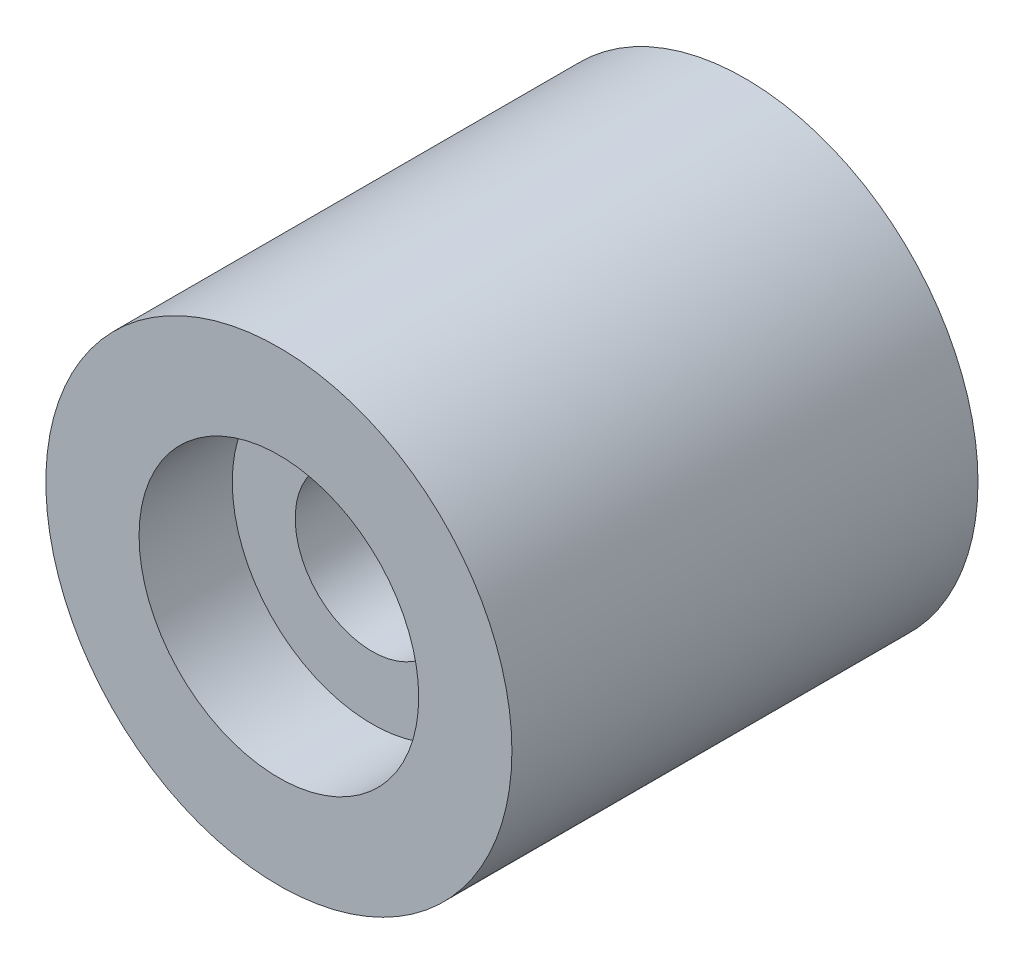
from build123d import *

# Parameters (mm, degrees)
SKETCH1_R           = 5
BOSS_EXTRUDE1_DEPTH = 10
SKETCH2_R           = 3
CUT_EXTRUDE1_DEPTH  = 2
SKETCH3_R           = 1.65
CUT_EXTRUDE2_DEPTH  = 14
SKETCH4_R           = 3
CUT_EXTRUDE3_DEPTH  = 2


with BuildPart() as part:
    # Sketch1 → Boss-Extrude1 (new body)
    with BuildSketch(Plane.XY):
        Circle(SKETCH1_R)
    extrude(amount=BOSS_EXTRUDE1_DEPTH)

    # Sketch2 → Cut-Extrude1 (cut)
    with BuildSketch(Plane.XY):
        Circle(SKETCH2_R)
    extrude(amount=CUT_EXTRUDE1_DEPTH, mode=Mode.SUBTRACT)

    # Sketch3 → Cut-Extrude2 (cut)
    with BuildSketch(Plane.XY):
        Circle(SKETCH3_R)
    extrude(amount=CUT_EXTRUDE2_DEPTH, mode=Mode.SUBTRACT)

    # Sketch4 → Cut-Extrude3 (cut)
    with BuildSketch(Plane.XY.offset(10)):
        Circle(SKETCH4_R)
    extrude(amount=-CUT_EXTRUDE3_DEPTH, mode=Mode.SUBTRACT)


solid = part.part
